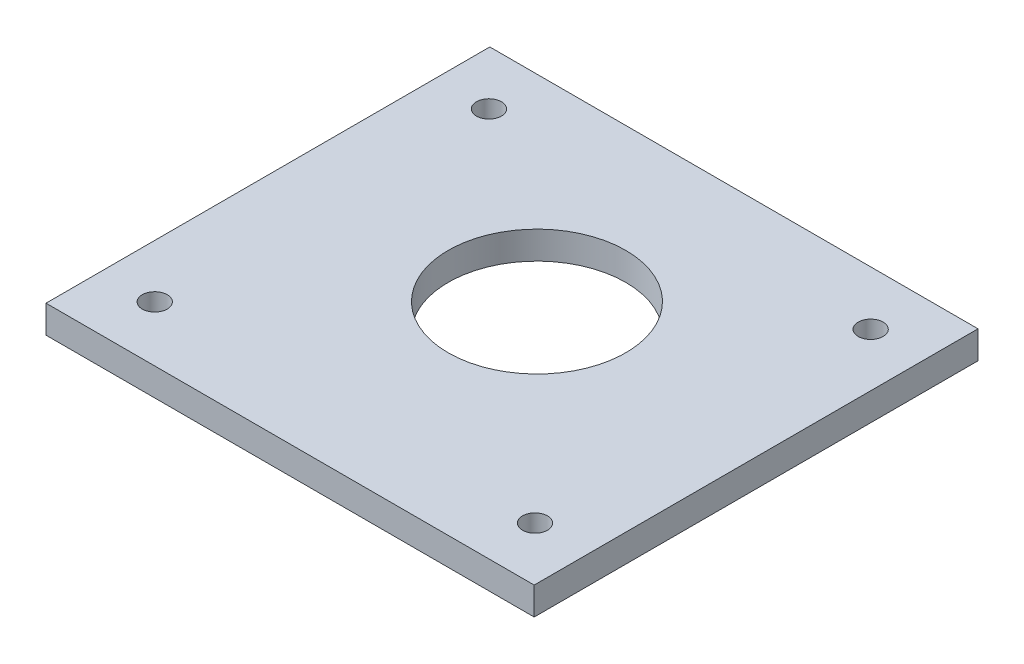
from build123d import *

# Parameters (mm, degrees)
SKETCH_1_W      = 88
SKETCH_1_H      = 80
SKETCH_1_R      = 2.25
SKETCH_1_R_2    = 16
EXTRUDE_1_DEPTH = 5


with BuildPart() as part:
    # Эскиз1 → Бобышка-Вытянуть1 (new body)
    with BuildSketch(Plane(origin=(0, 0, 0), x_dir=(1, 0, 0), z_dir=(0, 1, 0))):
        Rectangle(SKETCH_1_W, SKETCH_1_H)
        with Locations((-34.4, 30.25)):
            Circle(SKETCH_1_R, mode=Mode.SUBTRACT)
        with Locations((34.4, 30.25)):
            Circle(SKETCH_1_R, mode=Mode.SUBTRACT)
        with Locations((34.4, -30.25)):
            Circle(SKETCH_1_R, mode=Mode.SUBTRACT)
        with Locations((-34.4, -30)):
            Circle(SKETCH_1_R, mode=Mode.SUBTRACT)
        with Locations((0, 4.5)):
            Circle(SKETCH_1_R_2, mode=Mode.SUBTRACT)
    extrude(amount=EXTRUDE_1_DEPTH)


solid = part.part
